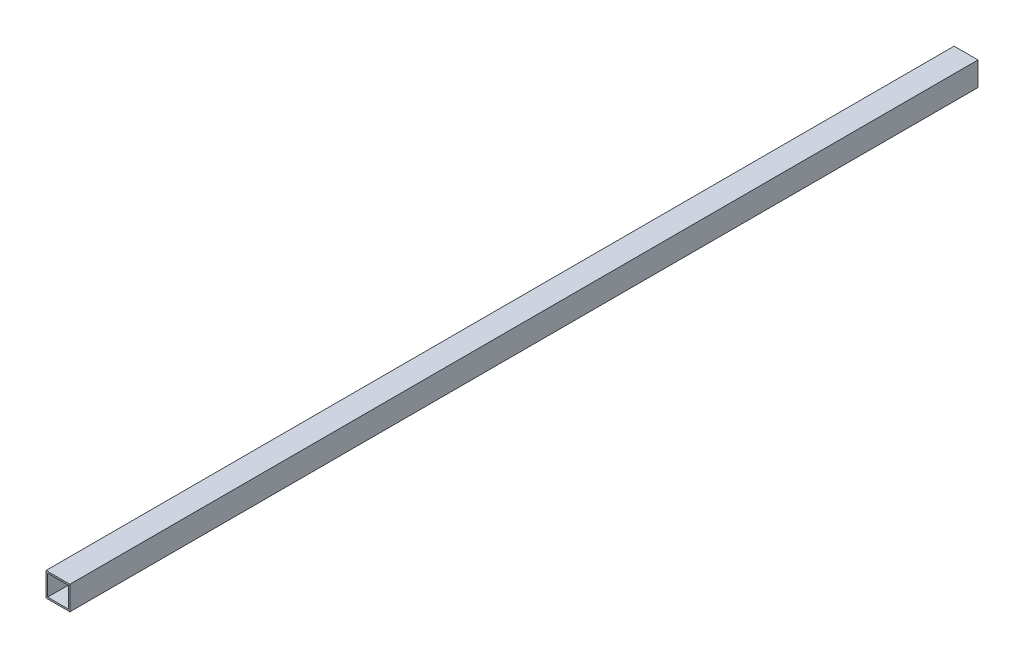
from build123d import *

# Parameters (mm, degrees)
SKETCH1_W   = 60
SKETCH1_H   = 60
SKETCH1_W_2 = 52
SKETCH1_H_2 = 52


with BuildPart() as part:
    # Sweep1: sweep along a curve in space
    with BuildLine() as sweep1_path:
        add(Edge.make_bspline(
            [(0, 0, -1140), (0, 0, 1140)],
            knots=[0, 0, 1, 1], degree=1))
    # Sketch1 → Sweep1 (sweep)
    with BuildSketch(Plane.XY):
        Rectangle(SKETCH1_W, SKETCH1_H)
        Rectangle(SKETCH1_W_2, SKETCH1_H_2, mode=Mode.SUBTRACT)
    sweep(path=sweep1_path.line)


solid = part.part
